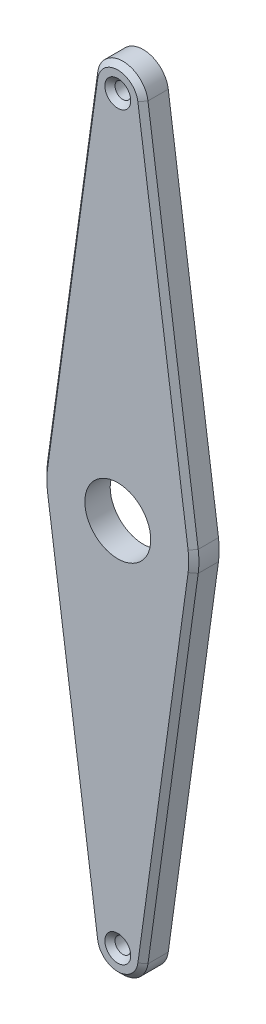
from build123d import *

# Parameters (mm, degrees)
BOSS_EXTRUDE1_DEPTH      = 5
CHAMFER1_SIZE            = 1
SKETCH6_R                = 1.55
CUT_EXTRUDE2_DEPTH       = 5
CHAMFER3_SIZE            = 1
CHAMFER3_OF_MIRROR2_SIZE = 1
CUT_EXTRUDE3_REACH       = 7
SKETCH10_R               = 6.5


with BuildPart() as part:
    # Sketch1 → Boss-Extrude1 (new body)
    with BuildSketch(Plane.XY):
        with BuildLine():
            ThreePointArc((100, 68), (99.964606776, 69.029827187), (99.858594129, 70.054794521))
            Line((99.858594129, 70.054794521), (89.95286471, 141.684931507))
            ThreePointArc((89.95286471, 141.684931507), (85, 146), (80.04713529, 141.684931507))
            Line((80.04713529, 141.684931507), (70.141405871, 70.054794521))
            ThreePointArc((70.141405871, 70.054794521), (70, 68), (70.141405871, 65.945205479))
            Line((70.141405871, 65.945205479), (80.04713529, -5.684931507))
            ThreePointArc((80.04713529, -5.684931507), (85, -10), (89.95286471, -5.684931507))
            Line((89.95286471, -5.684931507), (99.858594129, 65.945205479))
            ThreePointArc((99.858594129, 65.945205479), (99.964606776, 66.970172813), (100, 68))
        make_face()
    extrude(amount=BOSS_EXTRUDE1_DEPTH)

    # Chamfer1
    chamfer1_edges = [part.edges().sort_by_distance(p)[0] for p in [
        (100, 68, 5),
        (94.905729419, 105.869863014, 5),
        (85, 146, 5),
        (75.094270581, 105.869863014, 5),
        (70, 68, 5),
        (75.094270581, 30.130136986, 5),
        (85, -10, 5),
        (94.905729419, 30.130136986, 5),
    ]]
    chamfer(chamfer1_edges, length=CHAMFER1_SIZE)

    # Sketch6 → Cut-Extrude2 (cut)
    with BuildSketch(Plane.XY.offset(5)):
        with Locations((85, 141)):
            Circle(SKETCH6_R)
    cut_extrude2 = extrude(amount=-CUT_EXTRUDE2_DEPTH, mode=Mode.SUBTRACT)

    # Chamfer3
    chamfer3_edges = [part.edges().sort_by_distance(p)[0] for p in [
        (83.45, 141, 5),
    ]]
    chamfer(chamfer3_edges, length=CHAMFER3_SIZE)

    # Mirror2: Cut-Extrude2 across plane
    add(cut_extrude2.mirror(Plane(origin=(0, 68, 0), x_dir=(0, 0, 1), z_dir=(0, -1, 0))), mode=Mode.SUBTRACT)

    # Chamfer3 of Mirror2
    chamfer3_of_mirror2_edges = [part.edges().sort_by_distance(p)[0] for p in [
        (83.45, -5, 5),
    ]]
    chamfer(chamfer3_of_mirror2_edges, length=CHAMFER3_OF_MIRROR2_SIZE)

    # Sketch10 → Cut-Extrude3 (cut, up to next)
    with BuildSketch(Plane(origin=(0, 0, 0), x_dir=(-1, 0, 0), z_dir=(0, 0, -1)), mode=Mode.PRIVATE) as cut_extrude3_sk1:
        with Locations((-85, 68)):
            Circle(SKETCH10_R)
    cut_extrude3_tool1 = extrude(cut_extrude3_sk1.sketch, amount=-CUT_EXTRUDE3_REACH, mode=Mode.PRIVATE) & part.part
    add(cut_extrude3_tool1.solids().sort_by_distance((85, 68, 0))[0], mode=Mode.SUBTRACT)


solid = part.part
